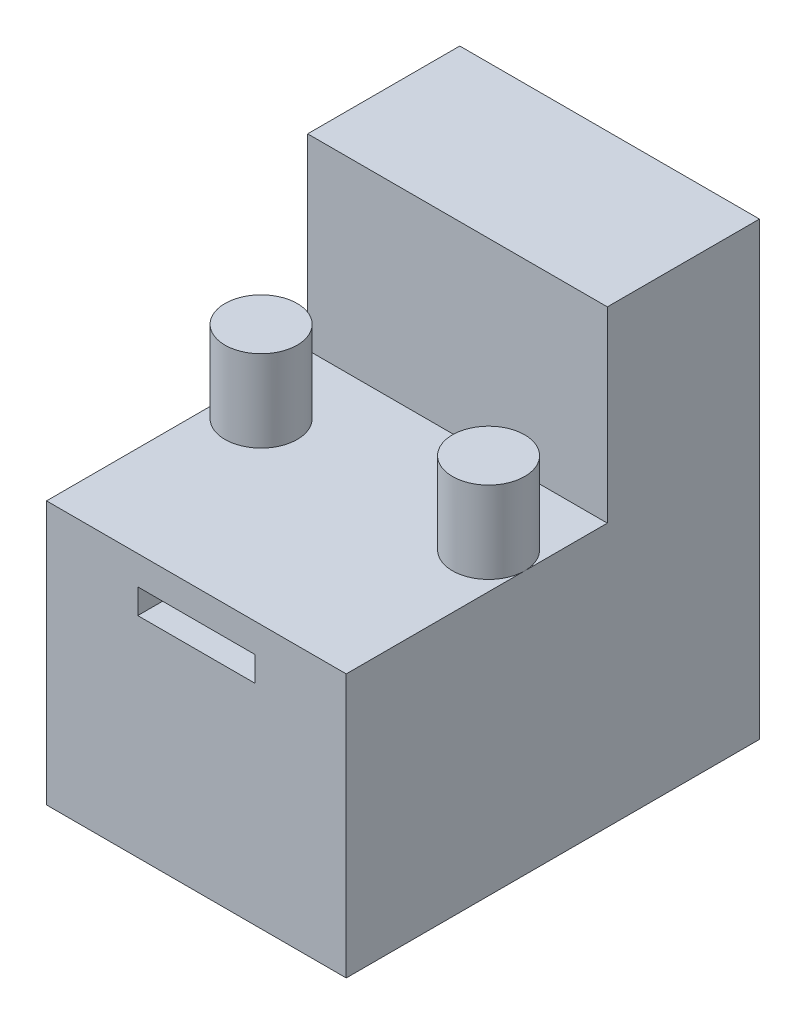
from build123d import *

# Parameters (mm, degrees)
SKETCH1_W           = 13.2
SKETCH1_H           = 18.2
BOSS_EXTRUDE1_DEPTH = 11.6
SKETCH2_R           = 1.59
BOSS_EXTRUDE2_DEPTH = 3.6
SKETCH3_W           = 13.2
SKETCH3_H           = 6.7
BOSS_EXTRUDE3_DEPTH = 8.25
SKETCH4_W           = 5.164958048
SKETCH4_H           = 1.096471541
CUT_EXTRUDE1_DEPTH  = 5


with BuildPart() as part:
    # Sketch1 → Boss-Extrude1 (new body)
    with BuildSketch(Plane(origin=(0, 0, 0), x_dir=(1, 0, 0), z_dir=(0, 1, 0))):
        Rectangle(SKETCH1_W, SKETCH1_H)
    extrude(amount=BOSS_EXTRUDE1_DEPTH)

    # Sketch2 → Boss-Extrude2 (add)
    with BuildSketch(Plane(origin=(0, 11.6, 0), x_dir=(1, 0, 0), z_dir=(0, 1, 0))):
        with Locations((-5.01, -1.24)):
            Circle(SKETCH2_R)
    boss_extrude2 = extrude(amount=BOSS_EXTRUDE2_DEPTH)

    # Mirror1: Boss-Extrude2 across plane
    add(boss_extrude2.mirror(Plane(origin=(0, 0, 0), x_dir=(0, 0, 1), z_dir=(1, 0, 0))))

    # Sketch3 → Boss-Extrude3 (add)
    with BuildSketch(Plane(origin=(0, 11.6, 0), x_dir=(1, 0, 0), z_dir=(0, 1, 0))):
        with Locations((0, 5.75)):
            Rectangle(SKETCH3_W, SKETCH3_H)
    extrude(amount=BOSS_EXTRUDE3_DEPTH)

    # Sketch4 → Cut-Extrude1 (cut)
    with BuildSketch(Plane.XY.offset(9.1)):
        with Locations((0, 9.780727429)):
            Rectangle(SKETCH4_W, SKETCH4_H)
    extrude(amount=-CUT_EXTRUDE1_DEPTH, mode=Mode.SUBTRACT)


solid = part.part
